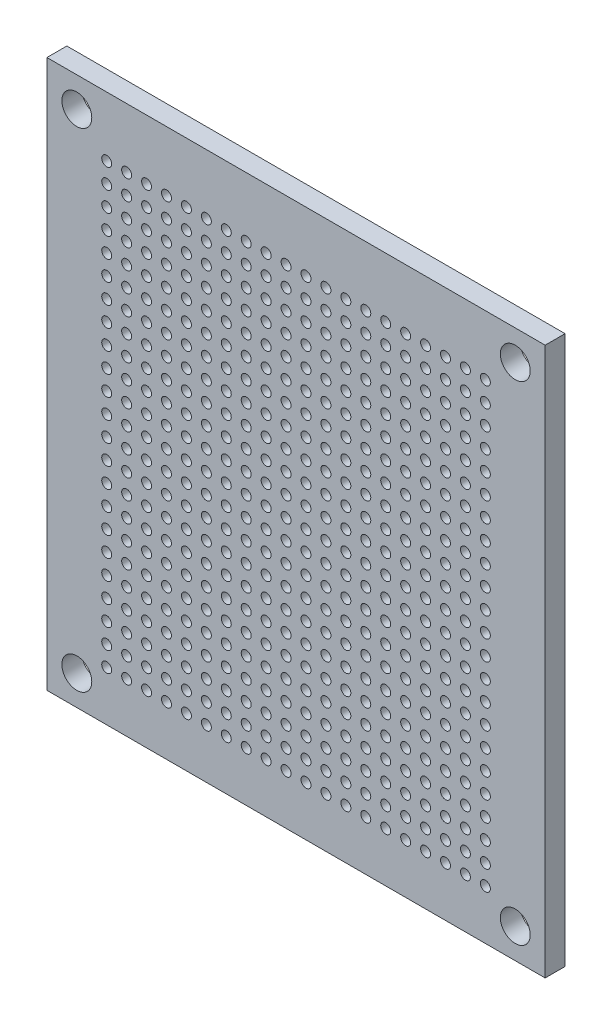
from build123d import *

# Parameters (mm, degrees)
ESQUISSE1_W        = 50
ESQUISSE1_H        = 55
ESQUISSE1_R        = 0.5
ESQUISSE1_R_2      = 1.5
BOSS_EXTRU_1_DEPTH = 2


with BuildPart() as part:
    # Esquisse1 → Boss.-Extru.1 (new body)
    with BuildSketch(Plane.XY):
        with Locations((25, 27.5)):
            Rectangle(ESQUISSE1_W, ESQUISSE1_H)
        with Locations((6, 49)):
            Circle(ESQUISSE1_R, mode=Mode.SUBTRACT)
        with Locations((3, 52)):
            Circle(ESQUISSE1_R_2, mode=Mode.SUBTRACT)
        with Locations((47, 52)):
            Circle(ESQUISSE1_R_2, mode=Mode.SUBTRACT)
        with Locations((3, 3)):
            Circle(ESQUISSE1_R_2, mode=Mode.SUBTRACT)
        with Locations((47, 3)):
            Circle(ESQUISSE1_R_2, mode=Mode.SUBTRACT)
        with Locations((8, 49)):
            Circle(ESQUISSE1_R, mode=Mode.SUBTRACT)
        with Locations((10, 49)):
            Circle(ESQUISSE1_R, mode=Mode.SUBTRACT)
        with Locations((12, 49)):
            Circle(ESQUISSE1_R, mode=Mode.SUBTRACT)
        with Locations((14, 49)):
            Circle(ESQUISSE1_R, mode=Mode.SUBTRACT)
        with Locations((16, 49)):
            Circle(ESQUISSE1_R, mode=Mode.SUBTRACT)
        with Locations((18, 49)):
            Circle(ESQUISSE1_R, mode=Mode.SUBTRACT)
        with Locations((20, 49)):
            Circle(ESQUISSE1_R, mode=Mode.SUBTRACT)
        with Locations((22, 49)):
            Circle(ESQUISSE1_R, mode=Mode.SUBTRACT)
        with Locations((24, 49)):
            Circle(ESQUISSE1_R, mode=Mode.SUBTRACT)
        with Locations((26, 49)):
            Circle(ESQUISSE1_R, mode=Mode.SUBTRACT)
        with Locations((28, 49)):
            Circle(ESQUISSE1_R, mode=Mode.SUBTRACT)
        with Locations((30, 49)):
            Circle(ESQUISSE1_R, mode=Mode.SUBTRACT)
        with Locations((32, 49)):
            Circle(ESQUISSE1_R, mode=Mode.SUBTRACT)
        with Locations((34, 49)):
            Circle(ESQUISSE1_R, mode=Mode.SUBTRACT)
        with Locations((36, 49)):
            Circle(ESQUISSE1_R, mode=Mode.SUBTRACT)
        with Locations((38, 49)):
            Circle(ESQUISSE1_R, mode=Mode.SUBTRACT)
        with Locations((40, 49)):
            Circle(ESQUISSE1_R, mode=Mode.SUBTRACT)
        with Locations((42, 49)):
            Circle(ESQUISSE1_R, mode=Mode.SUBTRACT)
        with Locations((44, 49)):
            Circle(ESQUISSE1_R, mode=Mode.SUBTRACT)
        with Locations((6, 9)):
            Circle(ESQUISSE1_R, mode=Mode.SUBTRACT)
        with Locations((8, 9)):
            Circle(ESQUISSE1_R, mode=Mode.SUBTRACT)
        with Locations((10, 9)):
            Circle(ESQUISSE1_R, mode=Mode.SUBTRACT)
        with Locations((12, 9)):
            Circle(ESQUISSE1_R, mode=Mode.SUBTRACT)
        with Locations((14, 9)):
            Circle(ESQUISSE1_R, mode=Mode.SUBTRACT)
        with Locations((8, 47)):
            Circle(ESQUISSE1_R, mode=Mode.SUBTRACT)
        with Locations((10, 47)):
            Circle(ESQUISSE1_R, mode=Mode.SUBTRACT)
        with Locations((12, 47)):
            Circle(ESQUISSE1_R, mode=Mode.SUBTRACT)
        with Locations((14, 47)):
            Circle(ESQUISSE1_R, mode=Mode.SUBTRACT)
        with Locations((16, 47)):
            Circle(ESQUISSE1_R, mode=Mode.SUBTRACT)
        with Locations((18, 47)):
            Circle(ESQUISSE1_R, mode=Mode.SUBTRACT)
        with Locations((20, 47)):
            Circle(ESQUISSE1_R, mode=Mode.SUBTRACT)
        with Locations((22, 47)):
            Circle(ESQUISSE1_R, mode=Mode.SUBTRACT)
        with Locations((24, 47)):
            Circle(ESQUISSE1_R, mode=Mode.SUBTRACT)
        with Locations((26, 47)):
            Circle(ESQUISSE1_R, mode=Mode.SUBTRACT)
        with Locations((28, 47)):
            Circle(ESQUISSE1_R, mode=Mode.SUBTRACT)
        with Locations((30, 47)):
            Circle(ESQUISSE1_R, mode=Mode.SUBTRACT)
        with Locations((32, 47)):
            Circle(ESQUISSE1_R, mode=Mode.SUBTRACT)
        with Locations((34, 47)):
            Circle(ESQUISSE1_R, mode=Mode.SUBTRACT)
        with Locations((36, 47)):
            Circle(ESQUISSE1_R, mode=Mode.SUBTRACT)
        with Locations((38, 47)):
            Circle(ESQUISSE1_R, mode=Mode.SUBTRACT)
        with Locations((40, 47)):
            Circle(ESQUISSE1_R, mode=Mode.SUBTRACT)
        with Locations((42, 47)):
            Circle(ESQUISSE1_R, mode=Mode.SUBTRACT)
        with Locations((44, 47)):
            Circle(ESQUISSE1_R, mode=Mode.SUBTRACT)
        with Locations((16, 9)):
            Circle(ESQUISSE1_R, mode=Mode.SUBTRACT)
        with Locations((18, 9)):
            Circle(ESQUISSE1_R, mode=Mode.SUBTRACT)
        with Locations((20, 9)):
            Circle(ESQUISSE1_R, mode=Mode.SUBTRACT)
        with Locations((22, 9)):
            Circle(ESQUISSE1_R, mode=Mode.SUBTRACT)
        with Locations((24, 9)):
            Circle(ESQUISSE1_R, mode=Mode.SUBTRACT)
        with Locations((8, 45)):
            Circle(ESQUISSE1_R, mode=Mode.SUBTRACT)
        with Locations((10, 45)):
            Circle(ESQUISSE1_R, mode=Mode.SUBTRACT)
        with Locations((12, 45)):
            Circle(ESQUISSE1_R, mode=Mode.SUBTRACT)
        with Locations((14, 45)):
            Circle(ESQUISSE1_R, mode=Mode.SUBTRACT)
        with Locations((16, 45)):
            Circle(ESQUISSE1_R, mode=Mode.SUBTRACT)
        with Locations((18, 45)):
            Circle(ESQUISSE1_R, mode=Mode.SUBTRACT)
        with Locations((20, 45)):
            Circle(ESQUISSE1_R, mode=Mode.SUBTRACT)
        with Locations((22, 45)):
            Circle(ESQUISSE1_R, mode=Mode.SUBTRACT)
        with Locations((24, 45)):
            Circle(ESQUISSE1_R, mode=Mode.SUBTRACT)
        with Locations((26, 45)):
            Circle(ESQUISSE1_R, mode=Mode.SUBTRACT)
        with Locations((28, 45)):
            Circle(ESQUISSE1_R, mode=Mode.SUBTRACT)
        with Locations((30, 45)):
            Circle(ESQUISSE1_R, mode=Mode.SUBTRACT)
        with Locations((32, 45)):
            Circle(ESQUISSE1_R, mode=Mode.SUBTRACT)
        with Locations((34, 45)):
            Circle(ESQUISSE1_R, mode=Mode.SUBTRACT)
        with Locations((36, 45)):
            Circle(ESQUISSE1_R, mode=Mode.SUBTRACT)
        with Locations((38, 45)):
            Circle(ESQUISSE1_R, mode=Mode.SUBTRACT)
        with Locations((40, 45)):
            Circle(ESQUISSE1_R, mode=Mode.SUBTRACT)
        with Locations((42, 45)):
            Circle(ESQUISSE1_R, mode=Mode.SUBTRACT)
        with Locations((44, 45)):
            Circle(ESQUISSE1_R, mode=Mode.SUBTRACT)
        with Locations((26, 9)):
            Circle(ESQUISSE1_R, mode=Mode.SUBTRACT)
        with Locations((28, 9)):
            Circle(ESQUISSE1_R, mode=Mode.SUBTRACT)
        with Locations((30, 9)):
            Circle(ESQUISSE1_R, mode=Mode.SUBTRACT)
        with Locations((32, 9)):
            Circle(ESQUISSE1_R, mode=Mode.SUBTRACT)
        with Locations((34, 9)):
            Circle(ESQUISSE1_R, mode=Mode.SUBTRACT)
        with Locations((8, 43)):
            Circle(ESQUISSE1_R, mode=Mode.SUBTRACT)
        with Locations((10, 43)):
            Circle(ESQUISSE1_R, mode=Mode.SUBTRACT)
        with Locations((12, 43)):
            Circle(ESQUISSE1_R, mode=Mode.SUBTRACT)
        with Locations((14, 43)):
            Circle(ESQUISSE1_R, mode=Mode.SUBTRACT)
        with Locations((16, 43)):
            Circle(ESQUISSE1_R, mode=Mode.SUBTRACT)
        with Locations((18, 43)):
            Circle(ESQUISSE1_R, mode=Mode.SUBTRACT)
        with Locations((20, 43)):
            Circle(ESQUISSE1_R, mode=Mode.SUBTRACT)
        with Locations((22, 43)):
            Circle(ESQUISSE1_R, mode=Mode.SUBTRACT)
        with Locations((24, 43)):
            Circle(ESQUISSE1_R, mode=Mode.SUBTRACT)
        with Locations((26, 43)):
            Circle(ESQUISSE1_R, mode=Mode.SUBTRACT)
        with Locations((28, 43)):
            Circle(ESQUISSE1_R, mode=Mode.SUBTRACT)
        with Locations((30, 43)):
            Circle(ESQUISSE1_R, mode=Mode.SUBTRACT)
        with Locations((32, 43)):
            Circle(ESQUISSE1_R, mode=Mode.SUBTRACT)
        with Locations((34, 43)):
            Circle(ESQUISSE1_R, mode=Mode.SUBTRACT)
        with Locations((36, 43)):
            Circle(ESQUISSE1_R, mode=Mode.SUBTRACT)
        with Locations((38, 43)):
            Circle(ESQUISSE1_R, mode=Mode.SUBTRACT)
        with Locations((40, 43)):
            Circle(ESQUISSE1_R, mode=Mode.SUBTRACT)
        with Locations((42, 43)):
            Circle(ESQUISSE1_R, mode=Mode.SUBTRACT)
        with Locations((44, 43)):
            Circle(ESQUISSE1_R, mode=Mode.SUBTRACT)
        with Locations((36, 9)):
            Circle(ESQUISSE1_R, mode=Mode.SUBTRACT)
        with Locations((38, 9)):
            Circle(ESQUISSE1_R, mode=Mode.SUBTRACT)
        with Locations((40, 9)):
            Circle(ESQUISSE1_R, mode=Mode.SUBTRACT)
        with Locations((42, 9)):
            Circle(ESQUISSE1_R, mode=Mode.SUBTRACT)
        with Locations((44, 9)):
            Circle(ESQUISSE1_R, mode=Mode.SUBTRACT)
        with Locations((8, 41)):
            Circle(ESQUISSE1_R, mode=Mode.SUBTRACT)
        with Locations((10, 41)):
            Circle(ESQUISSE1_R, mode=Mode.SUBTRACT)
        with Locations((12, 41)):
            Circle(ESQUISSE1_R, mode=Mode.SUBTRACT)
        with Locations((14, 41)):
            Circle(ESQUISSE1_R, mode=Mode.SUBTRACT)
        with Locations((16, 41)):
            Circle(ESQUISSE1_R, mode=Mode.SUBTRACT)
        with Locations((18, 41)):
            Circle(ESQUISSE1_R, mode=Mode.SUBTRACT)
        with Locations((20, 41)):
            Circle(ESQUISSE1_R, mode=Mode.SUBTRACT)
        with Locations((22, 41)):
            Circle(ESQUISSE1_R, mode=Mode.SUBTRACT)
        with Locations((24, 41)):
            Circle(ESQUISSE1_R, mode=Mode.SUBTRACT)
        with Locations((26, 41)):
            Circle(ESQUISSE1_R, mode=Mode.SUBTRACT)
        with Locations((28, 41)):
            Circle(ESQUISSE1_R, mode=Mode.SUBTRACT)
        with Locations((30, 41)):
            Circle(ESQUISSE1_R, mode=Mode.SUBTRACT)
        with Locations((32, 41)):
            Circle(ESQUISSE1_R, mode=Mode.SUBTRACT)
        with Locations((34, 41)):
            Circle(ESQUISSE1_R, mode=Mode.SUBTRACT)
        with Locations((36, 41)):
            Circle(ESQUISSE1_R, mode=Mode.SUBTRACT)
        with Locations((38, 41)):
            Circle(ESQUISSE1_R, mode=Mode.SUBTRACT)
        with Locations((40, 41)):
            Circle(ESQUISSE1_R, mode=Mode.SUBTRACT)
        with Locations((42, 41)):
            Circle(ESQUISSE1_R, mode=Mode.SUBTRACT)
        with Locations((44, 41)):
            Circle(ESQUISSE1_R, mode=Mode.SUBTRACT)
        with Locations((8, 39)):
            Circle(ESQUISSE1_R, mode=Mode.SUBTRACT)
        with Locations((10, 39)):
            Circle(ESQUISSE1_R, mode=Mode.SUBTRACT)
        with Locations((12, 39)):
            Circle(ESQUISSE1_R, mode=Mode.SUBTRACT)
        with Locations((14, 39)):
            Circle(ESQUISSE1_R, mode=Mode.SUBTRACT)
        with Locations((16, 39)):
            Circle(ESQUISSE1_R, mode=Mode.SUBTRACT)
        with Locations((18, 39)):
            Circle(ESQUISSE1_R, mode=Mode.SUBTRACT)
        with Locations((20, 39)):
            Circle(ESQUISSE1_R, mode=Mode.SUBTRACT)
        with Locations((22, 39)):
            Circle(ESQUISSE1_R, mode=Mode.SUBTRACT)
        with Locations((24, 39)):
            Circle(ESQUISSE1_R, mode=Mode.SUBTRACT)
        with Locations((26, 39)):
            Circle(ESQUISSE1_R, mode=Mode.SUBTRACT)
        with Locations((28, 39)):
            Circle(ESQUISSE1_R, mode=Mode.SUBTRACT)
        with Locations((30, 39)):
            Circle(ESQUISSE1_R, mode=Mode.SUBTRACT)
        with Locations((32, 39)):
            Circle(ESQUISSE1_R, mode=Mode.SUBTRACT)
        with Locations((34, 39)):
            Circle(ESQUISSE1_R, mode=Mode.SUBTRACT)
        with Locations((36, 39)):
            Circle(ESQUISSE1_R, mode=Mode.SUBTRACT)
        with Locations((38, 39)):
            Circle(ESQUISSE1_R, mode=Mode.SUBTRACT)
        with Locations((40, 39)):
            Circle(ESQUISSE1_R, mode=Mode.SUBTRACT)
        with Locations((42, 39)):
            Circle(ESQUISSE1_R, mode=Mode.SUBTRACT)
        with Locations((44, 39)):
            Circle(ESQUISSE1_R, mode=Mode.SUBTRACT)
        with Locations((6, 7)):
            Circle(ESQUISSE1_R, mode=Mode.SUBTRACT)
        with Locations((8, 7)):
            Circle(ESQUISSE1_R, mode=Mode.SUBTRACT)
        with Locations((10, 7)):
            Circle(ESQUISSE1_R, mode=Mode.SUBTRACT)
        with Locations((12, 7)):
            Circle(ESQUISSE1_R, mode=Mode.SUBTRACT)
        with Locations((14, 7)):
            Circle(ESQUISSE1_R, mode=Mode.SUBTRACT)
        with Locations((8, 37)):
            Circle(ESQUISSE1_R, mode=Mode.SUBTRACT)
        with Locations((10, 37)):
            Circle(ESQUISSE1_R, mode=Mode.SUBTRACT)
        with Locations((12, 37)):
            Circle(ESQUISSE1_R, mode=Mode.SUBTRACT)
        with Locations((14, 37)):
            Circle(ESQUISSE1_R, mode=Mode.SUBTRACT)
        with Locations((16, 37)):
            Circle(ESQUISSE1_R, mode=Mode.SUBTRACT)
        with Locations((18, 37)):
            Circle(ESQUISSE1_R, mode=Mode.SUBTRACT)
        with Locations((20, 37)):
            Circle(ESQUISSE1_R, mode=Mode.SUBTRACT)
        with Locations((22, 37)):
            Circle(ESQUISSE1_R, mode=Mode.SUBTRACT)
        with Locations((24, 37)):
            Circle(ESQUISSE1_R, mode=Mode.SUBTRACT)
        with Locations((26, 37)):
            Circle(ESQUISSE1_R, mode=Mode.SUBTRACT)
        with Locations((28, 37)):
            Circle(ESQUISSE1_R, mode=Mode.SUBTRACT)
        with Locations((30, 37)):
            Circle(ESQUISSE1_R, mode=Mode.SUBTRACT)
        with Locations((32, 37)):
            Circle(ESQUISSE1_R, mode=Mode.SUBTRACT)
        with Locations((34, 37)):
            Circle(ESQUISSE1_R, mode=Mode.SUBTRACT)
        with Locations((36, 37)):
            Circle(ESQUISSE1_R, mode=Mode.SUBTRACT)
        with Locations((38, 37)):
            Circle(ESQUISSE1_R, mode=Mode.SUBTRACT)
        with Locations((40, 37)):
            Circle(ESQUISSE1_R, mode=Mode.SUBTRACT)
        with Locations((42, 37)):
            Circle(ESQUISSE1_R, mode=Mode.SUBTRACT)
        with Locations((44, 37)):
            Circle(ESQUISSE1_R, mode=Mode.SUBTRACT)
        with Locations((16, 7)):
            Circle(ESQUISSE1_R, mode=Mode.SUBTRACT)
        with Locations((18, 7)):
            Circle(ESQUISSE1_R, mode=Mode.SUBTRACT)
        with Locations((20, 7)):
            Circle(ESQUISSE1_R, mode=Mode.SUBTRACT)
        with Locations((22, 7)):
            Circle(ESQUISSE1_R, mode=Mode.SUBTRACT)
        with Locations((24, 7)):
            Circle(ESQUISSE1_R, mode=Mode.SUBTRACT)
        with Locations((8, 35)):
            Circle(ESQUISSE1_R, mode=Mode.SUBTRACT)
        with Locations((10, 35)):
            Circle(ESQUISSE1_R, mode=Mode.SUBTRACT)
        with Locations((12, 35)):
            Circle(ESQUISSE1_R, mode=Mode.SUBTRACT)
        with Locations((14, 35)):
            Circle(ESQUISSE1_R, mode=Mode.SUBTRACT)
        with Locations((16, 35)):
            Circle(ESQUISSE1_R, mode=Mode.SUBTRACT)
        with Locations((18, 35)):
            Circle(ESQUISSE1_R, mode=Mode.SUBTRACT)
        with Locations((20, 35)):
            Circle(ESQUISSE1_R, mode=Mode.SUBTRACT)
        with Locations((22, 35)):
            Circle(ESQUISSE1_R, mode=Mode.SUBTRACT)
        with Locations((24, 35)):
            Circle(ESQUISSE1_R, mode=Mode.SUBTRACT)
        with Locations((26, 35)):
            Circle(ESQUISSE1_R, mode=Mode.SUBTRACT)
        with Locations((28, 35)):
            Circle(ESQUISSE1_R, mode=Mode.SUBTRACT)
        with Locations((30, 35)):
            Circle(ESQUISSE1_R, mode=Mode.SUBTRACT)
        with Locations((32, 35)):
            Circle(ESQUISSE1_R, mode=Mode.SUBTRACT)
        with Locations((34, 35)):
            Circle(ESQUISSE1_R, mode=Mode.SUBTRACT)
        with Locations((36, 35)):
            Circle(ESQUISSE1_R, mode=Mode.SUBTRACT)
        with Locations((38, 35)):
            Circle(ESQUISSE1_R, mode=Mode.SUBTRACT)
        with Locations((40, 35)):
            Circle(ESQUISSE1_R, mode=Mode.SUBTRACT)
        with Locations((42, 35)):
            Circle(ESQUISSE1_R, mode=Mode.SUBTRACT)
        with Locations((44, 35)):
            Circle(ESQUISSE1_R, mode=Mode.SUBTRACT)
        with Locations((26, 7)):
            Circle(ESQUISSE1_R, mode=Mode.SUBTRACT)
        with Locations((28, 7)):
            Circle(ESQUISSE1_R, mode=Mode.SUBTRACT)
        with Locations((30, 7)):
            Circle(ESQUISSE1_R, mode=Mode.SUBTRACT)
        with Locations((32, 7)):
            Circle(ESQUISSE1_R, mode=Mode.SUBTRACT)
        with Locations((34, 7)):
            Circle(ESQUISSE1_R, mode=Mode.SUBTRACT)
        with Locations((8, 33)):
            Circle(ESQUISSE1_R, mode=Mode.SUBTRACT)
        with Locations((10, 33)):
            Circle(ESQUISSE1_R, mode=Mode.SUBTRACT)
        with Locations((12, 33)):
            Circle(ESQUISSE1_R, mode=Mode.SUBTRACT)
        with Locations((14, 33)):
            Circle(ESQUISSE1_R, mode=Mode.SUBTRACT)
        with Locations((16, 33)):
            Circle(ESQUISSE1_R, mode=Mode.SUBTRACT)
        with Locations((18, 33)):
            Circle(ESQUISSE1_R, mode=Mode.SUBTRACT)
        with Locations((20, 33)):
            Circle(ESQUISSE1_R, mode=Mode.SUBTRACT)
        with Locations((22, 33)):
            Circle(ESQUISSE1_R, mode=Mode.SUBTRACT)
        with Locations((24, 33)):
            Circle(ESQUISSE1_R, mode=Mode.SUBTRACT)
        with Locations((26, 33)):
            Circle(ESQUISSE1_R, mode=Mode.SUBTRACT)
        with Locations((28, 33)):
            Circle(ESQUISSE1_R, mode=Mode.SUBTRACT)
        with Locations((30, 33)):
            Circle(ESQUISSE1_R, mode=Mode.SUBTRACT)
        with Locations((32, 33)):
            Circle(ESQUISSE1_R, mode=Mode.SUBTRACT)
        with Locations((34, 33)):
            Circle(ESQUISSE1_R, mode=Mode.SUBTRACT)
        with Locations((36, 33)):
            Circle(ESQUISSE1_R, mode=Mode.SUBTRACT)
        with Locations((38, 33)):
            Circle(ESQUISSE1_R, mode=Mode.SUBTRACT)
        with Locations((40, 33)):
            Circle(ESQUISSE1_R, mode=Mode.SUBTRACT)
        with Locations((42, 33)):
            Circle(ESQUISSE1_R, mode=Mode.SUBTRACT)
        with Locations((44, 33)):
            Circle(ESQUISSE1_R, mode=Mode.SUBTRACT)
        with Locations((36, 7)):
            Circle(ESQUISSE1_R, mode=Mode.SUBTRACT)
        with Locations((38, 7)):
            Circle(ESQUISSE1_R, mode=Mode.SUBTRACT)
        with Locations((40, 7)):
            Circle(ESQUISSE1_R, mode=Mode.SUBTRACT)
        with Locations((42, 7)):
            Circle(ESQUISSE1_R, mode=Mode.SUBTRACT)
        with Locations((44, 7)):
            Circle(ESQUISSE1_R, mode=Mode.SUBTRACT)
        with Locations((8, 31)):
            Circle(ESQUISSE1_R, mode=Mode.SUBTRACT)
        with Locations((10, 31)):
            Circle(ESQUISSE1_R, mode=Mode.SUBTRACT)
        with Locations((12, 31)):
            Circle(ESQUISSE1_R, mode=Mode.SUBTRACT)
        with Locations((14, 31)):
            Circle(ESQUISSE1_R, mode=Mode.SUBTRACT)
        with Locations((16, 31)):
            Circle(ESQUISSE1_R, mode=Mode.SUBTRACT)
        with Locations((18, 31)):
            Circle(ESQUISSE1_R, mode=Mode.SUBTRACT)
        with Locations((20, 31)):
            Circle(ESQUISSE1_R, mode=Mode.SUBTRACT)
        with Locations((22, 31)):
            Circle(ESQUISSE1_R, mode=Mode.SUBTRACT)
        with Locations((24, 31)):
            Circle(ESQUISSE1_R, mode=Mode.SUBTRACT)
        with Locations((26, 31)):
            Circle(ESQUISSE1_R, mode=Mode.SUBTRACT)
        with Locations((28, 31)):
            Circle(ESQUISSE1_R, mode=Mode.SUBTRACT)
        with Locations((30, 31)):
            Circle(ESQUISSE1_R, mode=Mode.SUBTRACT)
        with Locations((32, 31)):
            Circle(ESQUISSE1_R, mode=Mode.SUBTRACT)
        with Locations((34, 31)):
            Circle(ESQUISSE1_R, mode=Mode.SUBTRACT)
        with Locations((36, 31)):
            Circle(ESQUISSE1_R, mode=Mode.SUBTRACT)
        with Locations((38, 31)):
            Circle(ESQUISSE1_R, mode=Mode.SUBTRACT)
        with Locations((40, 31)):
            Circle(ESQUISSE1_R, mode=Mode.SUBTRACT)
        with Locations((42, 31)):
            Circle(ESQUISSE1_R, mode=Mode.SUBTRACT)
        with Locations((44, 31)):
            Circle(ESQUISSE1_R, mode=Mode.SUBTRACT)
        with Locations((8, 29)):
            Circle(ESQUISSE1_R, mode=Mode.SUBTRACT)
        with Locations((10, 29)):
            Circle(ESQUISSE1_R, mode=Mode.SUBTRACT)
        with Locations((12, 29)):
            Circle(ESQUISSE1_R, mode=Mode.SUBTRACT)
        with Locations((14, 29)):
            Circle(ESQUISSE1_R, mode=Mode.SUBTRACT)
        with Locations((16, 29)):
            Circle(ESQUISSE1_R, mode=Mode.SUBTRACT)
        with Locations((18, 29)):
            Circle(ESQUISSE1_R, mode=Mode.SUBTRACT)
        with Locations((20, 29)):
            Circle(ESQUISSE1_R, mode=Mode.SUBTRACT)
        with Locations((22, 29)):
            Circle(ESQUISSE1_R, mode=Mode.SUBTRACT)
        with Locations((24, 29)):
            Circle(ESQUISSE1_R, mode=Mode.SUBTRACT)
        with Locations((26, 29)):
            Circle(ESQUISSE1_R, mode=Mode.SUBTRACT)
        with Locations((28, 29)):
            Circle(ESQUISSE1_R, mode=Mode.SUBTRACT)
        with Locations((30, 29)):
            Circle(ESQUISSE1_R, mode=Mode.SUBTRACT)
        with Locations((32, 29)):
            Circle(ESQUISSE1_R, mode=Mode.SUBTRACT)
        with Locations((34, 29)):
            Circle(ESQUISSE1_R, mode=Mode.SUBTRACT)
        with Locations((36, 29)):
            Circle(ESQUISSE1_R, mode=Mode.SUBTRACT)
        with Locations((38, 29)):
            Circle(ESQUISSE1_R, mode=Mode.SUBTRACT)
        with Locations((40, 29)):
            Circle(ESQUISSE1_R, mode=Mode.SUBTRACT)
        with Locations((42, 29)):
            Circle(ESQUISSE1_R, mode=Mode.SUBTRACT)
        with Locations((44, 29)):
            Circle(ESQUISSE1_R, mode=Mode.SUBTRACT)
        with Locations((6, 5)):
            Circle(ESQUISSE1_R, mode=Mode.SUBTRACT)
        with Locations((8, 5)):
            Circle(ESQUISSE1_R, mode=Mode.SUBTRACT)
        with Locations((10, 5)):
            Circle(ESQUISSE1_R, mode=Mode.SUBTRACT)
        with Locations((12, 5)):
            Circle(ESQUISSE1_R, mode=Mode.SUBTRACT)
        with Locations((14, 5)):
            Circle(ESQUISSE1_R, mode=Mode.SUBTRACT)
        with Locations((8, 27)):
            Circle(ESQUISSE1_R, mode=Mode.SUBTRACT)
        with Locations((10, 27)):
            Circle(ESQUISSE1_R, mode=Mode.SUBTRACT)
        with Locations((12, 27)):
            Circle(ESQUISSE1_R, mode=Mode.SUBTRACT)
        with Locations((14, 27)):
            Circle(ESQUISSE1_R, mode=Mode.SUBTRACT)
        with Locations((16, 27)):
            Circle(ESQUISSE1_R, mode=Mode.SUBTRACT)
        with Locations((18, 27)):
            Circle(ESQUISSE1_R, mode=Mode.SUBTRACT)
        with Locations((20, 27)):
            Circle(ESQUISSE1_R, mode=Mode.SUBTRACT)
        with Locations((22, 27)):
            Circle(ESQUISSE1_R, mode=Mode.SUBTRACT)
        with Locations((24, 27)):
            Circle(ESQUISSE1_R, mode=Mode.SUBTRACT)
        with Locations((26, 27)):
            Circle(ESQUISSE1_R, mode=Mode.SUBTRACT)
        with Locations((28, 27)):
            Circle(ESQUISSE1_R, mode=Mode.SUBTRACT)
        with Locations((30, 27)):
            Circle(ESQUISSE1_R, mode=Mode.SUBTRACT)
        with Locations((32, 27)):
            Circle(ESQUISSE1_R, mode=Mode.SUBTRACT)
        with Locations((34, 27)):
            Circle(ESQUISSE1_R, mode=Mode.SUBTRACT)
        with Locations((36, 27)):
            Circle(ESQUISSE1_R, mode=Mode.SUBTRACT)
        with Locations((38, 27)):
            Circle(ESQUISSE1_R, mode=Mode.SUBTRACT)
        with Locations((40, 27)):
            Circle(ESQUISSE1_R, mode=Mode.SUBTRACT)
        with Locations((42, 27)):
            Circle(ESQUISSE1_R, mode=Mode.SUBTRACT)
        with Locations((44, 27)):
            Circle(ESQUISSE1_R, mode=Mode.SUBTRACT)
        with Locations((16, 5)):
            Circle(ESQUISSE1_R, mode=Mode.SUBTRACT)
        with Locations((18, 5)):
            Circle(ESQUISSE1_R, mode=Mode.SUBTRACT)
        with Locations((20, 5)):
            Circle(ESQUISSE1_R, mode=Mode.SUBTRACT)
        with Locations((22, 5)):
            Circle(ESQUISSE1_R, mode=Mode.SUBTRACT)
        with Locations((24, 5)):
            Circle(ESQUISSE1_R, mode=Mode.SUBTRACT)
        with Locations((8, 25)):
            Circle(ESQUISSE1_R, mode=Mode.SUBTRACT)
        with Locations((10, 25)):
            Circle(ESQUISSE1_R, mode=Mode.SUBTRACT)
        with Locations((12, 25)):
            Circle(ESQUISSE1_R, mode=Mode.SUBTRACT)
        with Locations((14, 25)):
            Circle(ESQUISSE1_R, mode=Mode.SUBTRACT)
        with Locations((16, 25)):
            Circle(ESQUISSE1_R, mode=Mode.SUBTRACT)
        with Locations((18, 25)):
            Circle(ESQUISSE1_R, mode=Mode.SUBTRACT)
        with Locations((20, 25)):
            Circle(ESQUISSE1_R, mode=Mode.SUBTRACT)
        with Locations((22, 25)):
            Circle(ESQUISSE1_R, mode=Mode.SUBTRACT)
        with Locations((24, 25)):
            Circle(ESQUISSE1_R, mode=Mode.SUBTRACT)
        with Locations((26, 25)):
            Circle(ESQUISSE1_R, mode=Mode.SUBTRACT)
        with Locations((28, 25)):
            Circle(ESQUISSE1_R, mode=Mode.SUBTRACT)
        with Locations((30, 25)):
            Circle(ESQUISSE1_R, mode=Mode.SUBTRACT)
        with Locations((32, 25)):
            Circle(ESQUISSE1_R, mode=Mode.SUBTRACT)
        with Locations((34, 25)):
            Circle(ESQUISSE1_R, mode=Mode.SUBTRACT)
        with Locations((36, 25)):
            Circle(ESQUISSE1_R, mode=Mode.SUBTRACT)
        with Locations((38, 25)):
            Circle(ESQUISSE1_R, mode=Mode.SUBTRACT)
        with Locations((40, 25)):
            Circle(ESQUISSE1_R, mode=Mode.SUBTRACT)
        with Locations((42, 25)):
            Circle(ESQUISSE1_R, mode=Mode.SUBTRACT)
        with Locations((44, 25)):
            Circle(ESQUISSE1_R, mode=Mode.SUBTRACT)
        with Locations((26, 5)):
            Circle(ESQUISSE1_R, mode=Mode.SUBTRACT)
        with Locations((28, 5)):
            Circle(ESQUISSE1_R, mode=Mode.SUBTRACT)
        with Locations((30, 5)):
            Circle(ESQUISSE1_R, mode=Mode.SUBTRACT)
        with Locations((32, 5)):
            Circle(ESQUISSE1_R, mode=Mode.SUBTRACT)
        with Locations((34, 5)):
            Circle(ESQUISSE1_R, mode=Mode.SUBTRACT)
        with Locations((8, 23)):
            Circle(ESQUISSE1_R, mode=Mode.SUBTRACT)
        with Locations((10, 23)):
            Circle(ESQUISSE1_R, mode=Mode.SUBTRACT)
        with Locations((12, 23)):
            Circle(ESQUISSE1_R, mode=Mode.SUBTRACT)
        with Locations((14, 23)):
            Circle(ESQUISSE1_R, mode=Mode.SUBTRACT)
        with Locations((16, 23)):
            Circle(ESQUISSE1_R, mode=Mode.SUBTRACT)
        with Locations((18, 23)):
            Circle(ESQUISSE1_R, mode=Mode.SUBTRACT)
        with Locations((20, 23)):
            Circle(ESQUISSE1_R, mode=Mode.SUBTRACT)
        with Locations((22, 23)):
            Circle(ESQUISSE1_R, mode=Mode.SUBTRACT)
        with Locations((24, 23)):
            Circle(ESQUISSE1_R, mode=Mode.SUBTRACT)
        with Locations((26, 23)):
            Circle(ESQUISSE1_R, mode=Mode.SUBTRACT)
        with Locations((28, 23)):
            Circle(ESQUISSE1_R, mode=Mode.SUBTRACT)
        with Locations((30, 23)):
            Circle(ESQUISSE1_R, mode=Mode.SUBTRACT)
        with Locations((32, 23)):
            Circle(ESQUISSE1_R, mode=Mode.SUBTRACT)
        with Locations((34, 23)):
            Circle(ESQUISSE1_R, mode=Mode.SUBTRACT)
        with Locations((36, 23)):
            Circle(ESQUISSE1_R, mode=Mode.SUBTRACT)
        with Locations((38, 23)):
            Circle(ESQUISSE1_R, mode=Mode.SUBTRACT)
        with Locations((40, 23)):
            Circle(ESQUISSE1_R, mode=Mode.SUBTRACT)
        with Locations((42, 23)):
            Circle(ESQUISSE1_R, mode=Mode.SUBTRACT)
        with Locations((44, 23)):
            Circle(ESQUISSE1_R, mode=Mode.SUBTRACT)
        with Locations((36, 5)):
            Circle(ESQUISSE1_R, mode=Mode.SUBTRACT)
        with Locations((38, 5)):
            Circle(ESQUISSE1_R, mode=Mode.SUBTRACT)
        with Locations((40, 5)):
            Circle(ESQUISSE1_R, mode=Mode.SUBTRACT)
        with Locations((42, 5)):
            Circle(ESQUISSE1_R, mode=Mode.SUBTRACT)
        with Locations((44, 5)):
            Circle(ESQUISSE1_R, mode=Mode.SUBTRACT)
        with Locations((8, 21)):
            Circle(ESQUISSE1_R, mode=Mode.SUBTRACT)
        with Locations((10, 21)):
            Circle(ESQUISSE1_R, mode=Mode.SUBTRACT)
        with Locations((12, 21)):
            Circle(ESQUISSE1_R, mode=Mode.SUBTRACT)
        with Locations((14, 21)):
            Circle(ESQUISSE1_R, mode=Mode.SUBTRACT)
        with Locations((16, 21)):
            Circle(ESQUISSE1_R, mode=Mode.SUBTRACT)
        with Locations((18, 21)):
            Circle(ESQUISSE1_R, mode=Mode.SUBTRACT)
        with Locations((20, 21)):
            Circle(ESQUISSE1_R, mode=Mode.SUBTRACT)
        with Locations((22, 21)):
            Circle(ESQUISSE1_R, mode=Mode.SUBTRACT)
        with Locations((24, 21)):
            Circle(ESQUISSE1_R, mode=Mode.SUBTRACT)
        with Locations((26, 21)):
            Circle(ESQUISSE1_R, mode=Mode.SUBTRACT)
        with Locations((28, 21)):
            Circle(ESQUISSE1_R, mode=Mode.SUBTRACT)
        with Locations((30, 21)):
            Circle(ESQUISSE1_R, mode=Mode.SUBTRACT)
        with Locations((32, 21)):
            Circle(ESQUISSE1_R, mode=Mode.SUBTRACT)
        with Locations((34, 21)):
            Circle(ESQUISSE1_R, mode=Mode.SUBTRACT)
        with Locations((36, 21)):
            Circle(ESQUISSE1_R, mode=Mode.SUBTRACT)
        with Locations((38, 21)):
            Circle(ESQUISSE1_R, mode=Mode.SUBTRACT)
        with Locations((40, 21)):
            Circle(ESQUISSE1_R, mode=Mode.SUBTRACT)
        with Locations((42, 21)):
            Circle(ESQUISSE1_R, mode=Mode.SUBTRACT)
        with Locations((44, 21)):
            Circle(ESQUISSE1_R, mode=Mode.SUBTRACT)
        with Locations((8, 19)):
            Circle(ESQUISSE1_R, mode=Mode.SUBTRACT)
        with Locations((10, 19)):
            Circle(ESQUISSE1_R, mode=Mode.SUBTRACT)
        with Locations((12, 19)):
            Circle(ESQUISSE1_R, mode=Mode.SUBTRACT)
        with Locations((14, 19)):
            Circle(ESQUISSE1_R, mode=Mode.SUBTRACT)
        with Locations((16, 19)):
            Circle(ESQUISSE1_R, mode=Mode.SUBTRACT)
        with Locations((18, 19)):
            Circle(ESQUISSE1_R, mode=Mode.SUBTRACT)
        with Locations((20, 19)):
            Circle(ESQUISSE1_R, mode=Mode.SUBTRACT)
        with Locations((22, 19)):
            Circle(ESQUISSE1_R, mode=Mode.SUBTRACT)
        with Locations((24, 19)):
            Circle(ESQUISSE1_R, mode=Mode.SUBTRACT)
        with Locations((26, 19)):
            Circle(ESQUISSE1_R, mode=Mode.SUBTRACT)
        with Locations((28, 19)):
            Circle(ESQUISSE1_R, mode=Mode.SUBTRACT)
        with Locations((30, 19)):
            Circle(ESQUISSE1_R, mode=Mode.SUBTRACT)
        with Locations((32, 19)):
            Circle(ESQUISSE1_R, mode=Mode.SUBTRACT)
        with Locations((34, 19)):
            Circle(ESQUISSE1_R, mode=Mode.SUBTRACT)
        with Locations((36, 19)):
            Circle(ESQUISSE1_R, mode=Mode.SUBTRACT)
        with Locations((38, 19)):
            Circle(ESQUISSE1_R, mode=Mode.SUBTRACT)
        with Locations((40, 19)):
            Circle(ESQUISSE1_R, mode=Mode.SUBTRACT)
        with Locations((42, 19)):
            Circle(ESQUISSE1_R, mode=Mode.SUBTRACT)
        with Locations((44, 19)):
            Circle(ESQUISSE1_R, mode=Mode.SUBTRACT)
        with Locations((8, 17)):
            Circle(ESQUISSE1_R, mode=Mode.SUBTRACT)
        with Locations((10, 17)):
            Circle(ESQUISSE1_R, mode=Mode.SUBTRACT)
        with Locations((12, 17)):
            Circle(ESQUISSE1_R, mode=Mode.SUBTRACT)
        with Locations((14, 17)):
            Circle(ESQUISSE1_R, mode=Mode.SUBTRACT)
        with Locations((16, 17)):
            Circle(ESQUISSE1_R, mode=Mode.SUBTRACT)
        with Locations((18, 17)):
            Circle(ESQUISSE1_R, mode=Mode.SUBTRACT)
        with Locations((20, 17)):
            Circle(ESQUISSE1_R, mode=Mode.SUBTRACT)
        with Locations((22, 17)):
            Circle(ESQUISSE1_R, mode=Mode.SUBTRACT)
        with Locations((24, 17)):
            Circle(ESQUISSE1_R, mode=Mode.SUBTRACT)
        with Locations((26, 17)):
            Circle(ESQUISSE1_R, mode=Mode.SUBTRACT)
        with Locations((28, 17)):
            Circle(ESQUISSE1_R, mode=Mode.SUBTRACT)
        with Locations((30, 17)):
            Circle(ESQUISSE1_R, mode=Mode.SUBTRACT)
        with Locations((32, 17)):
            Circle(ESQUISSE1_R, mode=Mode.SUBTRACT)
        with Locations((34, 17)):
            Circle(ESQUISSE1_R, mode=Mode.SUBTRACT)
        with Locations((36, 17)):
            Circle(ESQUISSE1_R, mode=Mode.SUBTRACT)
        with Locations((38, 17)):
            Circle(ESQUISSE1_R, mode=Mode.SUBTRACT)
        with Locations((40, 17)):
            Circle(ESQUISSE1_R, mode=Mode.SUBTRACT)
        with Locations((42, 17)):
            Circle(ESQUISSE1_R, mode=Mode.SUBTRACT)
        with Locations((44, 17)):
            Circle(ESQUISSE1_R, mode=Mode.SUBTRACT)
        with Locations((8, 15)):
            Circle(ESQUISSE1_R, mode=Mode.SUBTRACT)
        with Locations((10, 15)):
            Circle(ESQUISSE1_R, mode=Mode.SUBTRACT)
        with Locations((12, 15)):
            Circle(ESQUISSE1_R, mode=Mode.SUBTRACT)
        with Locations((14, 15)):
            Circle(ESQUISSE1_R, mode=Mode.SUBTRACT)
        with Locations((16, 15)):
            Circle(ESQUISSE1_R, mode=Mode.SUBTRACT)
        with Locations((18, 15)):
            Circle(ESQUISSE1_R, mode=Mode.SUBTRACT)
        with Locations((20, 15)):
            Circle(ESQUISSE1_R, mode=Mode.SUBTRACT)
        with Locations((22, 15)):
            Circle(ESQUISSE1_R, mode=Mode.SUBTRACT)
        with Locations((24, 15)):
            Circle(ESQUISSE1_R, mode=Mode.SUBTRACT)
        with Locations((26, 15)):
            Circle(ESQUISSE1_R, mode=Mode.SUBTRACT)
        with Locations((28, 15)):
            Circle(ESQUISSE1_R, mode=Mode.SUBTRACT)
        with Locations((30, 15)):
            Circle(ESQUISSE1_R, mode=Mode.SUBTRACT)
        with Locations((32, 15)):
            Circle(ESQUISSE1_R, mode=Mode.SUBTRACT)
        with Locations((34, 15)):
            Circle(ESQUISSE1_R, mode=Mode.SUBTRACT)
        with Locations((36, 15)):
            Circle(ESQUISSE1_R, mode=Mode.SUBTRACT)
        with Locations((38, 15)):
            Circle(ESQUISSE1_R, mode=Mode.SUBTRACT)
        with Locations((40, 15)):
            Circle(ESQUISSE1_R, mode=Mode.SUBTRACT)
        with Locations((42, 15)):
            Circle(ESQUISSE1_R, mode=Mode.SUBTRACT)
        with Locations((44, 15)):
            Circle(ESQUISSE1_R, mode=Mode.SUBTRACT)
        with Locations((6, 47)):
            Circle(ESQUISSE1_R, mode=Mode.SUBTRACT)
        with Locations((6, 45)):
            Circle(ESQUISSE1_R, mode=Mode.SUBTRACT)
        with Locations((6, 43)):
            Circle(ESQUISSE1_R, mode=Mode.SUBTRACT)
        with Locations((6, 41)):
            Circle(ESQUISSE1_R, mode=Mode.SUBTRACT)
        with Locations((6, 39)):
            Circle(ESQUISSE1_R, mode=Mode.SUBTRACT)
        with Locations((6, 37)):
            Circle(ESQUISSE1_R, mode=Mode.SUBTRACT)
        with Locations((6, 35)):
            Circle(ESQUISSE1_R, mode=Mode.SUBTRACT)
        with Locations((6, 33)):
            Circle(ESQUISSE1_R, mode=Mode.SUBTRACT)
        with Locations((6, 31)):
            Circle(ESQUISSE1_R, mode=Mode.SUBTRACT)
        with Locations((6, 29)):
            Circle(ESQUISSE1_R, mode=Mode.SUBTRACT)
        with Locations((6, 27)):
            Circle(ESQUISSE1_R, mode=Mode.SUBTRACT)
        with Locations((6, 25)):
            Circle(ESQUISSE1_R, mode=Mode.SUBTRACT)
        with Locations((6, 23)):
            Circle(ESQUISSE1_R, mode=Mode.SUBTRACT)
        with Locations((6, 21)):
            Circle(ESQUISSE1_R, mode=Mode.SUBTRACT)
        with Locations((6, 19)):
            Circle(ESQUISSE1_R, mode=Mode.SUBTRACT)
        with Locations((6, 17)):
            Circle(ESQUISSE1_R, mode=Mode.SUBTRACT)
        with Locations((6, 15)):
            Circle(ESQUISSE1_R, mode=Mode.SUBTRACT)
        with Locations((6, 13)):
            Circle(ESQUISSE1_R, mode=Mode.SUBTRACT)
        with Locations((8, 13)):
            Circle(ESQUISSE1_R, mode=Mode.SUBTRACT)
        with Locations((10, 13)):
            Circle(ESQUISSE1_R, mode=Mode.SUBTRACT)
        with Locations((12, 13)):
            Circle(ESQUISSE1_R, mode=Mode.SUBTRACT)
        with Locations((14, 13)):
            Circle(ESQUISSE1_R, mode=Mode.SUBTRACT)
        with Locations((16, 13)):
            Circle(ESQUISSE1_R, mode=Mode.SUBTRACT)
        with Locations((18, 13)):
            Circle(ESQUISSE1_R, mode=Mode.SUBTRACT)
        with Locations((20, 13)):
            Circle(ESQUISSE1_R, mode=Mode.SUBTRACT)
        with Locations((22, 13)):
            Circle(ESQUISSE1_R, mode=Mode.SUBTRACT)
        with Locations((24, 13)):
            Circle(ESQUISSE1_R, mode=Mode.SUBTRACT)
        with Locations((26, 13)):
            Circle(ESQUISSE1_R, mode=Mode.SUBTRACT)
        with Locations((28, 13)):
            Circle(ESQUISSE1_R, mode=Mode.SUBTRACT)
        with Locations((30, 13)):
            Circle(ESQUISSE1_R, mode=Mode.SUBTRACT)
        with Locations((32, 13)):
            Circle(ESQUISSE1_R, mode=Mode.SUBTRACT)
        with Locations((34, 13)):
            Circle(ESQUISSE1_R, mode=Mode.SUBTRACT)
        with Locations((36, 13)):
            Circle(ESQUISSE1_R, mode=Mode.SUBTRACT)
        with Locations((38, 13)):
            Circle(ESQUISSE1_R, mode=Mode.SUBTRACT)
        with Locations((40, 13)):
            Circle(ESQUISSE1_R, mode=Mode.SUBTRACT)
        with Locations((42, 13)):
            Circle(ESQUISSE1_R, mode=Mode.SUBTRACT)
        with Locations((44, 13)):
            Circle(ESQUISSE1_R, mode=Mode.SUBTRACT)
        with Locations((6, 11)):
            Circle(ESQUISSE1_R, mode=Mode.SUBTRACT)
        with Locations((8, 11)):
            Circle(ESQUISSE1_R, mode=Mode.SUBTRACT)
        with Locations((10, 11)):
            Circle(ESQUISSE1_R, mode=Mode.SUBTRACT)
        with Locations((12, 11)):
            Circle(ESQUISSE1_R, mode=Mode.SUBTRACT)
        with Locations((14, 11)):
            Circle(ESQUISSE1_R, mode=Mode.SUBTRACT)
        with Locations((16, 11)):
            Circle(ESQUISSE1_R, mode=Mode.SUBTRACT)
        with Locations((18, 11)):
            Circle(ESQUISSE1_R, mode=Mode.SUBTRACT)
        with Locations((20, 11)):
            Circle(ESQUISSE1_R, mode=Mode.SUBTRACT)
        with Locations((22, 11)):
            Circle(ESQUISSE1_R, mode=Mode.SUBTRACT)
        with Locations((24, 11)):
            Circle(ESQUISSE1_R, mode=Mode.SUBTRACT)
        with Locations((26, 11)):
            Circle(ESQUISSE1_R, mode=Mode.SUBTRACT)
        with Locations((28, 11)):
            Circle(ESQUISSE1_R, mode=Mode.SUBTRACT)
        with Locations((30, 11)):
            Circle(ESQUISSE1_R, mode=Mode.SUBTRACT)
        with Locations((32, 11)):
            Circle(ESQUISSE1_R, mode=Mode.SUBTRACT)
        with Locations((34, 11)):
            Circle(ESQUISSE1_R, mode=Mode.SUBTRACT)
        with Locations((36, 11)):
            Circle(ESQUISSE1_R, mode=Mode.SUBTRACT)
        with Locations((38, 11)):
            Circle(ESQUISSE1_R, mode=Mode.SUBTRACT)
        with Locations((40, 11)):
            Circle(ESQUISSE1_R, mode=Mode.SUBTRACT)
        with Locations((42, 11)):
            Circle(ESQUISSE1_R, mode=Mode.SUBTRACT)
        with Locations((44, 11)):
            Circle(ESQUISSE1_R, mode=Mode.SUBTRACT)
    extrude(amount=BOSS_EXTRU_1_DEPTH)


solid = part.part
